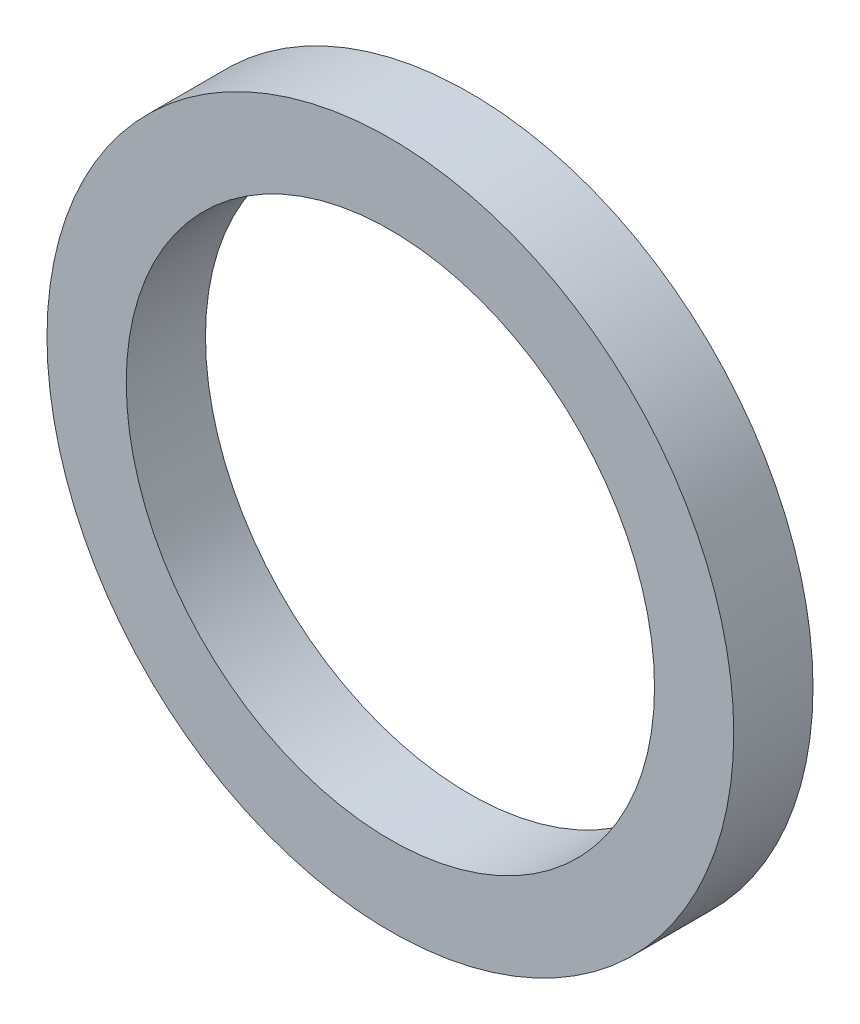
from build123d import *

# Parameters (mm, degrees)
SKETCH1_R           = 13
SKETCH1_R_2         = 10
BOSS_EXTRUDE1_DEPTH = 3


with BuildPart() as part:
    # Sketch1 → Boss-Extrude1 (new body)
    with BuildSketch(Plane.XY):
        Circle(SKETCH1_R)
        Circle(SKETCH1_R_2, mode=Mode.SUBTRACT)
    extrude(amount=BOSS_EXTRUDE1_DEPTH)


solid = part.part
